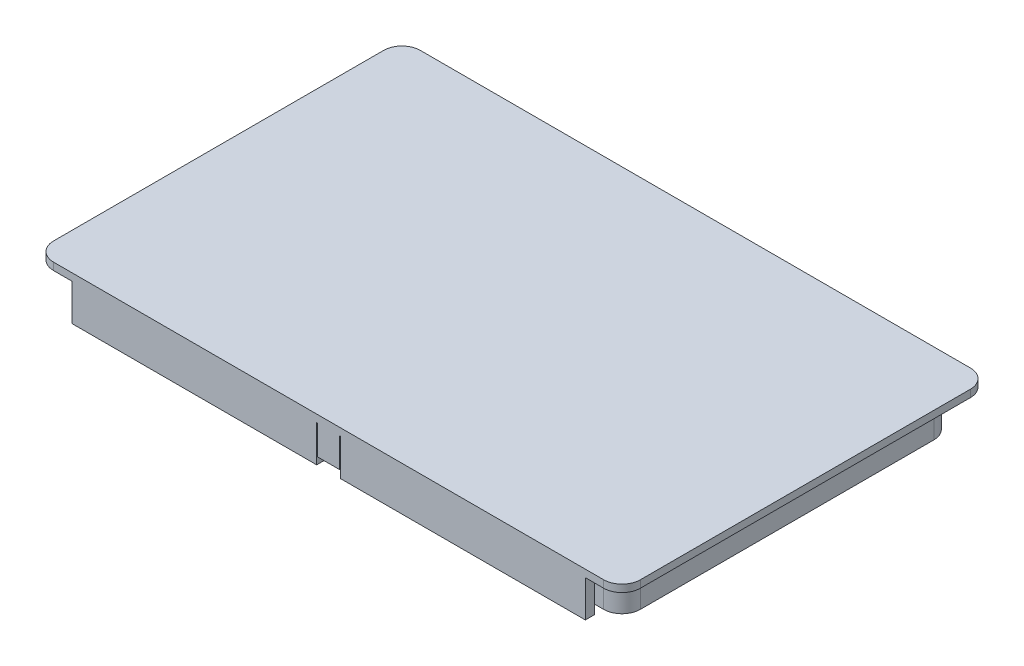
from build123d import *

# Parameters (mm, degrees)
BOSS_EXTRUDE1_DEPTH = 12
SKETCH6_OUTSIDE_W   = 199.812
SKETCH6_OUTSIDE_H   = 139.812
SKETCH6_OUTSIDE_W_2 = 140
SKETCH6_OUTSIDE_H_2 = 2.5
CUT_EXTRUDE1_DEPTH  = 10
SKETCH7_W           = 140
SKETCH7_H           = 80
CUT_EXTRUDE2_DEPTH  = 10
SKETCH13_W          = 6.5
SKETCH13_H          = 10
CUT_EXTRUDE3_DEPTH  = 5
BOSS_EXTRUDE2_DEPTH = 3


with BuildPart() as part:
    # Sketch3 → Boss-Extrude1 (new body)
    with BuildSketch(Plane(origin=(0, 0, 0), x_dir=(1, 0, 0), z_dir=(0, 1, 0))):
        with BuildLine():
            Line((75, -50), (-75, -50))
            ThreePointArc((-75, -50), (-78.535533906, -48.535533906), (-80, -45))
            Line((-80, -45), (-80, 45))
            ThreePointArc((-80, 45), (-78.535533906, 48.535533906), (-75, 50))
            Line((-75, 50), (75, 50))
            ThreePointArc((75, 50), (78.535533906, 48.535533906), (80, 45))
            Line((80, 45), (80, -45))
            ThreePointArc((80, -45), (78.535533906, -48.535533906), (75, -50))
        make_face()
    extrude(amount=-BOSS_EXTRUDE1_DEPTH)

    # Sketch6 outside → Cut-Extrude1 (cut)
    with BuildSketch(Plane.XZ.offset(12)):
        Rectangle(SKETCH6_OUTSIDE_W, SKETCH6_OUTSIDE_H)
        with BuildLine():
            Line((70, -45), (-70, -45))
            ThreePointArc((-70, -45), (-73.535533906, -43.535533906), (-75, -40))
            Line((-75, -40), (-75, 40))
            ThreePointArc((-75, 40), (-73.535533906, 43.535533906), (-70, 45))
            Line((-70, 45), (70, 45))
            ThreePointArc((70, 45), (73.535533906, 43.535533906), (75, 40))
            Line((75, 40), (75, -40))
            ThreePointArc((75, -40), (73.535533906, -43.535533906), (70, -45))
        make_face(mode=Mode.SUBTRACT)
        with Locations((0, 48.75)):
            Rectangle(SKETCH6_OUTSIDE_W_2, SKETCH6_OUTSIDE_H_2, mode=Mode.SUBTRACT)
        with Locations((0, -48.75)):
            Rectangle(SKETCH6_OUTSIDE_W_2, SKETCH6_OUTSIDE_H_2, mode=Mode.SUBTRACT)
    extrude(amount=-CUT_EXTRUDE1_DEPTH, mode=Mode.SUBTRACT)

    # Sketch7 → Cut-Extrude2 (cut)
    with BuildSketch(Plane.XZ.offset(12)):
        Rectangle(SKETCH7_W, SKETCH7_H)
    extrude(amount=-CUT_EXTRUDE2_DEPTH, mode=Mode.SUBTRACT)

    # Sketch13 → Cut-Extrude3 (cut)
    with BuildSketch(Plane(origin=(0, 0, -50), x_dir=(-1, 0, 0), z_dir=(0, 0, -1))):
        with Locations((0, -7)):
            Rectangle(SKETCH13_W, SKETCH13_H)
    cut_extrude3 = extrude(amount=-CUT_EXTRUDE3_DEPTH, mode=Mode.SUBTRACT)

    # Sketch14 → Boss-Extrude2 (add, symmetric)
    with BuildSketch(Plane(origin=(0, 0, 0), x_dir=(0, 0, -1), z_dir=(1, 0, 0))):
        Polygon((50, -2), (50, -5.8), (50, -10), (49.25, -10), (49.25, -5.85), (48.5, -5.1), (48.5, -4.6), (49, -4.6), (49, -2), align=None)
    boss_extrude2 = extrude(amount=BOSS_EXTRUDE2_DEPTH, both=True)

    # Mirror1: Cut-Extrude3, Boss-Extrude2 across plane
    add(cut_extrude3.mirror(Plane.XY), mode=Mode.SUBTRACT)
    add(boss_extrude2.mirror(Plane.XY))


solid = part.part
